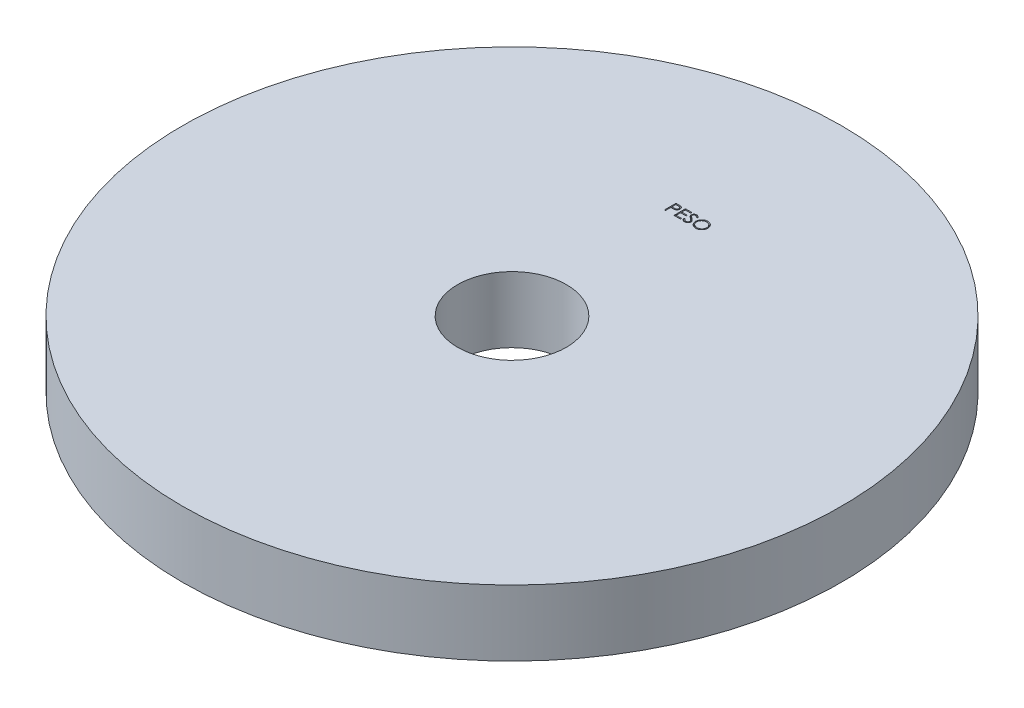
from build123d import *

# Parameters (mm, degrees)
ESBO_O1_R                = 100
ESBO_O1_R_2              = 16.5
RESSALTO_EXTRUS_O1_DEPTH = 20
CORTE_EXTRUS_O1_DEPTH    = 1


with BuildPart() as part:
    # Esboço1 → Ressalto-extrusão1 (new body)
    with BuildSketch(Plane(origin=(0, 0, 0), x_dir=(1, 0, 0), z_dir=(0, 1, 0))):
        Circle(ESBO_O1_R)
        Circle(ESBO_O1_R_2, mode=Mode.SUBTRACT)
    extrude(amount=RESSALTO_EXTRUS_O1_DEPTH)

    # Esboço2 → Corte-extrusão1 (cut)
    with BuildSketch(Plane(origin=(0, 20, 0), x_dir=(1, 0, 0), z_dir=(0, 1, 0))):
        with BuildLine():
            Line((-4.728102869, 54.494159365), (-4.041704632, 54.494159365))
            add(Edge.make_bspline(
                [(-4.041704632, 54.494159365), (-3.994493726, 54.494107469), (-3.904035533, 54.494008034), (-3.774320477, 54.490993288), (-3.656510746, 54.486966596), (-3.550860365, 54.481384703), (-3.457044267, 54.474788112), (-3.375486967, 54.465536073), (-3.305547411, 54.455875777), (-3.263640961, 54.446054371), (-3.244529151, 54.441575231)],
                knots=[0, 0, 0, 0, 0.000141628, 0.000271366, 0.00038923, 0.000495248, 0.00058876, 0.000671296, 0.000741499, 0.00080036, 0.00080036, 0.00080036, 0.00080036], degree=3))
            add(Edge.make_bspline(
                [(-3.244529151, 54.441575231), (-3.220335617, 54.434953281), (-3.17251864, 54.421865419), (-3.103617597, 54.395651696), (-3.038063752, 54.364569531), (-2.975632193, 54.329145591), (-2.91709011, 54.287860027), (-2.861564069, 54.242386409), (-2.809544089, 54.19167484), (-2.761322697, 54.1362941), (-2.717037899, 54.077173891), (-2.678908217, 54.013431661), (-2.64698099, 53.946140357), (-2.619597718, 53.875346786), (-2.599889264, 53.800456463), (-2.585042364, 53.72198975), (-2.575618736, 53.63995506), (-2.574716175, 53.583895192), (-2.574256715, 53.555357282)],
                knots=[0, 0, 0, 0, 7.5216e-05, 0.00014866, 0.000220794, 0.000292713, 0.000363707, 0.000435434, 0.000507823, 0.000581364, 0.000655543, 0.000729131, 0.000803767, 0.000878771, 0.000956497, 0.001035702, 0.001118238, 0.001203821, 0.001203821, 0.001203821, 0.001203821], degree=3))
            add(Edge.make_bspline(
                [(-2.574256715, 53.555357282), (-2.57467814, 53.526579505), (-2.575502686, 53.470273841), (-2.585398971, 53.387901053), (-2.598729163, 53.309182663), (-2.619226215, 53.234293213), (-2.646071888, 53.163677442), (-2.677563941, 53.09625621), (-2.715547472, 53.033176538), (-2.759192301, 52.974209421), (-2.807743896, 52.919299508), (-2.860996834, 52.868844714), (-2.918736126, 52.823140375), (-2.980778274, 52.782084032), (-3.047728123, 52.746627752), (-3.118570277, 52.714870447), (-3.193920493, 52.688199387), (-3.246063007, 52.674169325), (-3.272574023, 52.667035968)],
                knots=[0, 0, 0, 0, 8.6284e-05, 0.00016882, 0.000248587, 0.000325638, 0.000401297, 0.000474998, 0.000548586, 0.000621785, 0.0006948, 0.0007682, 0.000841564, 0.000915458, 0.000991056, 0.00106858, 0.00114819, 0.001230532, 0.001230532, 0.001230532, 0.001230532], degree=3))
            add(Edge.make_bspline(
                [(-3.272574023, 52.667035968), (-3.294501357, 52.662372987), (-3.342556384, 52.652153793), (-3.421699106, 52.640745336), (-3.513844492, 52.631007735), (-3.618866772, 52.623706598), (-3.736671677, 52.617456229), (-3.867322935, 52.612488135), (-4.011077012, 52.609758281), (-4.111348256, 52.609617489), (-4.163699824, 52.609543981)],
                knots=[0, 0, 0, 0, 6.7238e-05, 0.000147357, 0.000239727, 0.000345177, 0.000463135, 0.000593636, 0.000737393, 0.000894446, 0.000894446, 0.000894446, 0.000894446], degree=3))
            Line((-4.163699824, 52.609543981), (-4.414000305, 52.609543981))
            Line((-4.414000305, 52.609543981), (-4.414000305, 50.994159365))
            Line((-4.414000305, 50.994159365), (-4.728102869, 50.994159365))
            Line((-4.728102869, 50.994159365), (-4.728102869, 54.494159365))
        make_face()
        with BuildLine():
            Line((-4.414000305, 54.135185006), (-4.414000305, 52.96851834))
            Line((-4.414000305, 52.96851834), (-3.801219856, 52.960806))
            add(Edge.make_bspline(
                [(-3.801219856, 52.960806), (-3.77129993, 52.960790536), (-3.713540131, 52.960760684), (-3.630103907, 52.964745908), (-3.55269462, 52.96934644), (-3.481550045, 52.976082364), (-3.41663811, 52.985603621), (-3.357850581, 52.995215359), (-3.305643298, 53.009120722), (-3.244544097, 53.027843791), (-3.176460749, 53.059776407), (-3.102393201, 53.106126297), (-3.039622614, 53.165207005), (-2.985304317, 53.231634836), (-2.94219844, 53.305533966), (-2.910642447, 53.384602902), (-2.89210129, 53.468030752), (-2.889615096, 53.525118891), (-2.888359279, 53.553955039)],
                knots=[0, 0, 0, 0, 8.9746e-05, 0.000173253, 0.000250533, 0.00032239, 0.000387534, 0.00044736, 0.000500926, 0.000549486, 0.000638903, 0.000725641, 0.000810488, 0.000896226, 0.000982324, 0.00106604, 0.001150757, 0.001237226, 0.001237226, 0.001237226, 0.001237226], degree=3))
            add(Edge.make_bspline(
                [(-2.888359279, 53.553955039), (-2.889621926, 53.582093552), (-2.892131911, 53.638029434), (-2.910787774, 53.720008195), (-2.942137088, 53.798243899), (-2.985593682, 53.871216984), (-3.038334812, 53.937405788), (-3.099634155, 53.994902916), (-3.169347417, 54.041124618), (-3.234195648, 54.0709579), (-3.291796834, 54.089173175), (-3.341828794, 54.101918016), (-3.398319468, 54.112093622), (-3.461287248, 54.120333125), (-3.530244082, 54.127386586), (-3.605782396, 54.132172563), (-3.68761604, 54.13497402), (-3.744426611, 54.135112975), (-3.773876106, 54.135185006)],
                knots=[0, 0, 0, 0, 8.4371e-05, 0.000167719, 0.000250783, 0.000336277, 0.000421575, 0.000503926, 0.000587348, 0.000671427, 0.000717102, 0.000768457, 0.000826213, 0.000889178, 0.000958942, 0.001034123, 0.001116202, 0.001204546, 0.001204546, 0.001204546, 0.001204546], degree=3))
            Line((-3.773876106, 54.135185006), (-4.414000305, 54.135185006))
        make_face(mode=Mode.SUBTRACT)
        Polygon((-1.856307997, 54.494159365), (0.118050977, 54.494159365), (0.118050977, 54.135185006), (-1.542205433, 54.135185006), (-1.542205433, 53.05826193), (0.118050977, 53.05826193), (0.118050977, 52.699287571), (-1.542205433, 52.699287571), (-1.542205433, 51.353133724), (0.118050977, 51.353133724), (0.118050977, 50.994159365), (-1.856307997, 50.994159365), align=None)
        with BuildLine():
            Line((0.387281746, 51.669339654), (0.683155144, 51.846723468))
            add(Edge.make_bspline(
                [(0.683155144, 51.846723468), (0.710673381, 51.800659083), (0.763397262, 51.712401499), (0.851348621, 51.593143459), (0.942481532, 51.491781302), (1.037470865, 51.408904694), (1.135736814, 51.343655808), (1.237920867, 51.297453576), (1.343678678, 51.268637601), (1.4156525, 51.265137514), (1.451584631, 51.263390135)],
                knots=[0, 0, 0, 0, 0.000160901, 0.00030828, 0.000443778, 0.00056903, 0.000685513, 0.000796284, 0.00090427, 0.001011928, 0.001011928, 0.001011928, 0.001011928], degree=3))
            add(Edge.make_bspline(
                [(1.451584631, 51.263390135), (1.482271491, 51.264244807), (1.543108264, 51.265939197), (1.632670507, 51.282219999), (1.71965231, 51.307232128), (1.802260947, 51.34305306), (1.879356562, 51.386391546), (1.946963257, 51.438737723), (2.00540937, 51.497343929), (2.053218485, 51.562726584), (2.08989852, 51.633043732), (2.118090589, 51.705219683), (2.133735662, 51.780388252), (2.136092416, 51.830998715), (2.137281746, 51.856539173)],
                knots=[0, 0, 0, 0, 9.1978e-05, 0.000182347, 0.000272202, 0.000362975, 0.000451852, 0.000536835, 0.000618639, 0.000699414, 0.000778765, 0.000855983, 0.0009312, 0.001007828, 0.001007828, 0.001007828, 0.001007828], degree=3))
            add(Edge.make_bspline(
                [(2.137281746, 51.856539173), (2.135807436, 51.885680023), (2.132810377, 51.944919112), (2.107478897, 52.032318765), (2.06762965, 52.118811335), (2.030867007, 52.172312601), (2.011780945, 52.200088853)],
                knots=[0, 0, 0, 0, 8.7281e-05, 0.000177429, 0.000270909, 0.000371844, 0.000371844, 0.000371844, 0.000371844], degree=3))
            add(Edge.make_bspline(
                [(2.011780945, 52.200088853), (1.996110331, 52.220135676), (1.963211837, 52.262221475), (1.906654324, 52.32486671), (1.84028821, 52.389485129), (1.766384655, 52.458544186), (1.682251566, 52.528831983), (1.590524051, 52.603700261), (1.488860193, 52.680301838), (1.417560696, 52.731674403), (1.38077133, 52.758181801)],
                knots=[0, 0, 0, 0, 7.6319e-05, 0.000160223, 0.000252933, 0.000354147, 0.000463581, 0.000581729, 0.000709336, 0.000845369, 0.000845369, 0.000845369, 0.000845369], degree=3))
            add(Edge.make_bspline(
                [(1.38077133, 52.758181801), (1.343947333, 52.784410389), (1.273542657, 52.834557451), (1.175084075, 52.908981735), (1.087039612, 52.977025605), (1.009800595, 53.039329617), (0.943400998, 53.095902222), (0.887317587, 53.146200161), (0.84297903, 53.191583722), (0.818323449, 53.221025063), (0.807253701, 53.2342435)],
                knots=[0, 0, 0, 0, 0.000135623, 0.000259301, 0.000370234, 0.000469439, 0.00055697, 0.000631911, 0.000695377, 0.00074709, 0.00074709, 0.00074709, 0.00074709], degree=3))
            add(Edge.make_bspline(
                [(0.807253701, 53.2342435), (0.791781156, 53.254844537), (0.761352319, 53.295359241), (0.721186314, 53.358684098), (0.687047151, 53.423507364), (0.660284819, 53.490003228), (0.6377486, 53.557238157), (0.62259067, 53.626089403), (0.613099273, 53.696248021), (0.612127286, 53.743461522), (0.611640721, 53.767096064)],
                knots=[0, 0, 0, 0, 7.727e-05, 0.000151962, 0.000224716, 0.000296717, 0.00036678, 0.0004372, 0.000507902, 0.000578771, 0.000578771, 0.000578771, 0.000578771], degree=3))
            add(Edge.make_bspline(
                [(0.611640721, 53.767096064), (0.61294593, 53.804125839), (0.61552845, 53.877393902), (0.637368967, 53.984424733), (0.671841861, 54.08661115), (0.720136748, 54.182941484), (0.782394101, 54.270907465), (0.854440076, 54.351520952), (0.940251562, 54.419289534), (1.034404185, 54.478501592), (1.137460557, 54.524847518), (1.245451461, 54.559808498), (1.358548533, 54.579617755), (1.435151667, 54.58246052), (1.474020528, 54.583902955)],
                knots=[0, 0, 0, 0, 0.000110999, 0.000219625, 0.000326272, 0.00043382, 0.000541574, 0.000648775, 0.000756959, 0.000868438, 0.000981703, 0.00109501, 0.001208203, 0.0013248, 0.0013248, 0.0013248, 0.0013248], degree=3))
            add(Edge.make_bspline(
                [(1.474020528, 54.583902955), (1.515264629, 54.582480404), (1.59728598, 54.579651402), (1.717935196, 54.555053871), (1.834095912, 54.514353199), (1.927539177, 54.468164541), (2.000671939, 54.422033126), (2.056444671, 54.380013301), (2.112962122, 54.331638193), (2.170680177, 54.276778947), (2.228620836, 54.214932196), (2.287644289, 54.146521507), (2.347888557, 54.071964951), (2.386644418, 54.01874045), (2.406512516, 53.991455039)],
                knots=[0, 0, 0, 0, 0.000123638, 0.000245877, 0.000367608, 0.000492088, 0.000557638, 0.000626769, 0.000701372, 0.00078072, 0.000865532, 0.000955497, 0.001051745, 0.001152989, 0.001152989, 0.001152989, 0.001152989], degree=3))
            Line((2.406512516, 53.991455039), (2.122558189, 53.776210647))
            add(Edge.make_bspline(
                [(2.122558189, 53.776210647), (2.105412256, 53.798299338), (2.072393199, 53.840836991), (2.022263712, 53.900408307), (1.975015064, 53.954824786), (1.928464664, 54.002089914), (1.885071033, 54.044792048), (1.842953991, 54.081351804), (1.80271964, 54.1121274), (1.752002729, 54.14497096), (1.688285011, 54.177527463), (1.608300474, 54.205076541), (1.524714199, 54.221631603), (1.467784568, 54.223820491), (1.438964439, 54.224928596)],
                knots=[0, 0, 0, 0, 8.3877e-05, 0.000161528, 0.000233552, 0.000299993, 0.000360485, 0.000416152, 0.000467195, 0.000512312, 0.000597287, 0.000681099, 0.000765389, 0.000851809, 0.000851809, 0.000851809, 0.000851809], degree=3))
            add(Edge.make_bspline(
                [(1.438964439, 54.224928596), (1.402807916, 54.223716896), (1.333083469, 54.221380247), (1.234093233, 54.195860262), (1.144999308, 54.155678401), (1.068446743, 54.099363423), (1.004709766, 54.032642431), (0.958604307, 53.955863576), (0.930854142, 53.871081173), (0.927467863, 53.811939517), (0.925743285, 53.781819622)],
                knots=[0, 0, 0, 0, 0.000108248, 0.000208746, 0.00030443, 0.000399793, 0.000492054, 0.00057947, 0.000666386, 0.000756591, 0.000756591, 0.000756591, 0.000756591], degree=3))
            add(Edge.make_bspline(
                [(0.925743285, 53.781819622), (0.926136411, 53.763068143), (0.926923307, 53.725534524), (0.937898105, 53.670083102), (0.951997434, 53.614771763), (0.974340066, 53.55984918), (1.00518537, 53.504354821), (1.045690545, 53.447333083), (1.096703857, 53.388281374), (1.13578087, 53.349874001), (1.156412355, 53.329596064)],
                knots=[0, 0, 0, 0, 5.616e-05, 0.000112411, 0.000169046, 0.000227244, 0.000289691, 0.000359134, 0.000436702, 0.000523463, 0.000523463, 0.000523463, 0.000523463], degree=3))
            add(Edge.make_bspline(
                [(1.156412355, 53.329596064), (1.164073728, 53.322759038), (1.182275395, 53.30651583), (1.215551321, 53.279923549), (1.259494119, 53.247120777), (1.31295632, 53.206533461), (1.376923682, 53.159451998), (1.451403238, 53.106478386), (1.535564771, 53.045892927), (1.595286687, 53.003535387), (1.62686508, 52.981138532)],
                knots=[0, 0, 0, 0, 3.0802e-05, 7.3177e-05, 0.000127725, 0.000195314, 0.000274544, 0.000365991, 0.000469501, 0.000585644, 0.000585644, 0.000585644, 0.000585644], degree=3))
            add(Edge.make_bspline(
                [(1.62686508, 52.981138532), (1.664850993, 52.953497173), (1.738405449, 52.899973511), (1.843063029, 52.819557831), (1.937956837, 52.740910062), (2.023420041, 52.664532455), (2.100296949, 52.591004362), (2.16773467, 52.519441182), (2.22642035, 52.450355609), (2.289599569, 52.361783033), (2.354157388, 52.253001949), (2.409598896, 52.119723711), (2.444557243, 51.98592739), (2.449128759, 51.896000554), (2.45138431, 51.851631321)],
                knots=[0, 0, 0, 0, 0.000140932, 0.000272896, 0.000395881, 0.000510584, 0.000616697, 0.000714904, 0.000805482, 0.000888372, 0.001041088, 0.001183793, 0.001320341, 0.001453327, 0.001453327, 0.001453327, 0.001453327], degree=3))
            add(Edge.make_bspline(
                [(2.45138431, 51.851631321), (2.450727172, 51.820252955), (2.449425657, 51.758105572), (2.434464743, 51.666850495), (2.412545078, 51.578219625), (2.379507844, 51.493308513), (2.339184686, 51.41056375), (2.288018438, 51.33215585), (2.228710753, 51.256349451), (2.160676989, 51.18516596), (2.086231086, 51.119819764), (2.007547392, 51.061690702), (1.924497119, 51.013222379), (1.837530802, 50.973671537), (1.746628465, 50.942738019), (1.651820681, 50.92032515), (1.55295117, 50.906569439), (1.485750689, 50.905141678), (1.451584631, 50.904415776)],
                knots=[0, 0, 0, 0, 9.4044e-05, 0.000186263, 0.000276729, 0.000367488, 0.000459046, 0.000552398, 0.000647774, 0.000747454, 0.000847311, 0.000944634, 0.001040472, 0.001135227, 0.001230788, 0.001328063, 0.00142712, 0.00152957, 0.00152957, 0.00152957, 0.00152957], degree=3))
            add(Edge.make_bspline(
                [(1.451584631, 50.904415776), (1.425149288, 50.904926957), (1.372611528, 50.905942883), (1.294902046, 50.914924163), (1.218762457, 50.927631267), (1.145148175, 50.947805337), (1.073110763, 50.972282314), (1.002963529, 51.002420646), (0.934672475, 51.038537848), (0.867854892, 51.079832872), (0.802680717, 51.127890617), (0.739761249, 51.183864113), (0.677032064, 51.246209618), (0.616344668, 51.316620182), (0.556471523, 51.393958265), (0.498593114, 51.478947448), (0.441511396, 51.571124802), (0.405695928, 51.635989887), (0.387281746, 51.669339654)],
                knots=[0, 0, 0, 0, 7.9276e-05, 0.000157554, 0.000234438, 0.000310629, 0.000386236, 0.000462555, 0.000539392, 0.000617798, 0.000698008, 0.000781971, 0.000870217, 0.00096315, 0.001060616, 0.001163492, 0.001271478, 0.00138575, 0.00138575, 0.00138575, 0.00138575], degree=3))
        make_face()
        with BuildLine():
            add(Edge.make_bspline(
                [(4.807153541, 54.583902955), (4.871961647, 54.582261476), (4.999250114, 54.579037475), (5.186325012, 54.554358371), (5.364920107, 54.511662981), (5.536490246, 54.454799999), (5.698983222, 54.378945614), (5.853622115, 54.287260465), (6.000038989, 54.178784006), (6.13626037, 54.05435478), (6.260917321, 53.918971326), (6.370743207, 53.774493416), (6.462785501, 53.621794613), (6.538371288, 53.461333783), (6.597669897, 53.293473815), (6.638588941, 53.117319812), (6.664727091, 52.934013122), (6.667782869, 52.808986257), (6.669333028, 52.745561609)],
                knots=[0, 0, 0, 0, 0.000194393, 0.000381804, 0.00056479, 0.000744601, 0.000923091, 0.001101652, 0.001283106, 0.001468738, 0.001654324, 0.001834514, 0.002012231, 0.002188181, 0.002365797, 0.002545211, 0.002729936, 0.002920126, 0.002920126, 0.002920126, 0.002920126], degree=3))
            add(Edge.make_bspline(
                [(6.669333028, 52.745561609), (6.667783096, 52.682604163), (6.664727999, 52.558507742), (6.638559222, 52.376364298), (6.597518222, 52.201273602), (6.538921956, 52.033527949), (6.463696477, 51.872950385), (6.371041306, 51.719963431), (6.261900095, 51.574516933), (6.137693244, 51.438204268), (6.002292202, 51.313206797), (5.857061935, 51.204287921), (5.705268615, 51.110563797), (5.544958907, 51.035780123), (5.37825887, 50.976008202), (5.203676547, 50.935255572), (5.022029993, 50.908968529), (4.89815899, 50.905950013), (4.835198413, 50.904415776)],
                knots=[0, 0, 0, 0, 0.000188789, 0.000372126, 0.000550857, 0.00072758, 0.000904164, 0.001081881, 0.001263191, 0.001448823, 0.00163441, 0.001815159, 0.001992641, 0.002168591, 0.002344885, 0.002522934, 0.002705576, 0.002894365, 0.002894365, 0.002894365, 0.002894365], degree=3))
            add(Edge.make_bspline(
                [(4.835198413, 50.904415776), (4.771774094, 50.905965163), (4.646747878, 50.909019416), (4.463210843, 50.935200821), (4.286933099, 50.976142125), (4.118418748, 51.034651561), (3.957573818, 51.110268792), (3.804083735, 51.202473171), (3.658564588, 51.311880312), (3.522222842, 51.436046887), (3.397473643, 51.571218439), (3.288714268, 51.716052694), (3.196489154, 51.867708151), (3.121125822, 52.026605675), (3.061461363, 52.191977117), (3.020756544, 52.364925595), (2.994420592, 52.544465101), (2.991385746, 52.666707999), (2.989845849, 52.728734686)],
                knots=[0, 0, 0, 0, 0.00019019, 0.000374915, 0.000555011, 0.000732396, 0.00090898, 0.001087298, 0.001268608, 0.00145424, 0.001639827, 0.001819595, 0.001996712, 0.002171394, 0.002346367, 0.002523053, 0.002703612, 0.002889599, 0.002889599, 0.002889599, 0.002889599], degree=3))
            add(Edge.make_bspline(
                [(2.989845849, 52.728734686), (2.990380484, 52.770367355), (2.991443011, 52.853107479), (3.004234703, 52.975974079), (3.022796404, 53.096864737), (3.049398317, 53.215435684), (3.084189984, 53.331396669), (3.125242011, 53.445547432), (3.175381857, 53.556731156), (3.232062505, 53.665474547), (3.295324313, 53.770082453), (3.365200062, 53.868962036), (3.439235431, 53.962943033), (3.520398824, 54.049590037), (3.606015269, 54.131423693), (3.697473648, 54.20718641), (3.794215892, 54.277561361), (3.896658272, 54.340981703), (4.002276547, 54.398340837), (4.111153324, 54.447562688), (4.221809896, 54.48980875), (4.334764544, 54.524049575), (4.449717316, 54.551081611), (4.5669191, 54.569488965), (4.686276527, 54.582313282), (4.766687846, 54.583370784), (4.807153541, 54.583902955)],
                knots=[0, 0, 0, 0, 0.000124849, 0.000248123, 0.000370193, 0.00049164, 0.000612319, 0.000733199, 0.000855287, 0.000977905, 0.001100913, 0.001221706, 0.001340948, 0.001459521, 0.001577551, 0.001696047, 0.001815534, 0.001936153, 0.002057243, 0.002175846, 0.002294342, 0.002412335, 0.002529682, 0.00264829, 0.002768075, 0.00288942, 0.00288942, 0.00288942, 0.00288942], degree=3))
        make_face()
        with BuildLine():
            add(Edge.make_bspline(
                [(4.822578221, 54.224928596), (4.789363587, 54.224523706), (4.723251854, 54.223717796), (4.624967318, 54.213102081), (4.527975384, 54.197972192), (4.432256022, 54.176390671), (4.338209733, 54.146986618), (4.244959891, 54.11314571), (4.153356838, 54.071924619), (4.06370298, 54.025351915), (3.976787904, 53.973802994), (3.894775203, 53.916831227), (3.817452559, 53.855772673), (3.745009292, 53.790484836), (3.67765812, 53.720635234), (3.614073419, 53.647282798), (3.556803837, 53.568330907), (3.50431826, 53.4859205), (3.45735042, 53.400158919), (3.415585065, 53.311949056), (3.381421057, 53.220571369), (3.35355868, 53.127017212), (3.330458869, 53.031434752), (3.315824945, 52.933098903), (3.305092586, 52.832503791), (3.30433274, 52.764521937), (3.303948413, 52.73013693)],
                knots=[0, 0, 0, 0, 9.9599e-05, 0.000198245, 0.000296222, 0.00039402, 0.00049227, 0.000591646, 0.000691452, 0.000793368, 0.000894612, 0.000994383, 0.001092713, 0.00119001, 0.001286696, 0.001383657, 0.001480979, 0.001579008, 0.001676595, 0.001774142, 0.001871547, 0.001968922, 0.002066879, 0.00216624, 0.00226698, 0.002370083, 0.002370083, 0.002370083, 0.002370083], degree=3))
            add(Edge.make_bspline(
                [(3.303948413, 52.73013693), (3.305223275, 52.679574709), (3.307731323, 52.580103178), (3.329688893, 52.434335035), (3.363510867, 52.294246748), (3.413368234, 52.160604839), (3.475718848, 52.032260556), (3.552745739, 51.910352451), (3.644004824, 51.794847577), (3.747668351, 51.686552308), (3.860991057, 51.587706504), (3.981323787, 51.500943095), (4.107377395, 51.427532845), (4.239480598, 51.367727773), (4.376928137, 51.320338035), (4.520605688, 51.287859404), (4.669556147, 51.266483949), (4.771086802, 51.264431193), (4.822578221, 51.263390135)],
                knots=[0, 0, 0, 0, 0.000151605, 0.000298253, 0.000441263, 0.000583229, 0.000725274, 0.000868635, 0.001014928, 0.001166177, 0.001317744, 0.00146543, 0.001610576, 0.001754594, 0.001899821, 0.002045914, 0.002195936, 0.002350312, 0.002350312, 0.002350312, 0.002350312], degree=3))
            add(Edge.make_bspline(
                [(4.822578221, 51.263390135), (4.857187722, 51.263865639), (4.925828759, 51.264808707), (5.027924281, 51.274307384), (5.128180493, 51.289539253), (5.226456773, 51.311469909), (5.322641584, 51.338917115), (5.417136387, 51.371524843), (5.508934677, 51.412206047), (5.599194515, 51.457153999), (5.685590757, 51.508394156), (5.768066289, 51.563432306), (5.844542269, 51.624400926), (5.91693134, 51.688718739), (5.984559029, 51.757682587), (6.046968014, 51.831202809), (6.103948146, 51.909743466), (6.156413792, 51.992028872), (6.203217055, 52.078025124), (6.243996154, 52.166554802), (6.27859227, 52.257399912), (6.306520775, 52.350691483), (6.328406237, 52.446252332), (6.343486157, 52.54421041), (6.354034595, 52.644369753), (6.354829672, 52.712113609), (6.355230464, 52.746262731)],
                knots=[0, 0, 0, 0, 0.000103804, 0.000205874, 0.000307314, 0.000407849, 0.000507719, 0.000607281, 0.000707445, 0.000808723, 0.000909609, 0.001008589, 0.001105934, 0.001202762, 0.001298946, 0.001395452, 0.001491794, 0.001589823, 0.001688026, 0.001785277, 0.001882027, 0.001979402, 0.0020772, 0.002175869, 0.002276609, 0.002379011, 0.002379011, 0.002379011, 0.002379011], degree=3))
            add(Edge.make_bspline(
                [(6.355230464, 52.746262731), (6.354829351, 52.780178235), (6.35403367, 52.847455885), (6.343491195, 52.946916704), (6.328390305, 53.044169915), (6.306627597, 53.138833718), (6.278577443, 53.230932243), (6.243990113, 53.320378991), (6.203204813, 53.407507186), (6.156396589, 53.492101483), (6.103780765, 53.573276221), (6.046286522, 53.650878633), (5.982921174, 53.723451375), (5.915495149, 53.792786069), (5.842324264, 53.857403958), (5.76373997, 53.917326479), (5.680696292, 53.973999753), (5.592769056, 54.025125315), (5.502025103, 54.072339548), (5.408911145, 54.112790551), (5.314482045, 54.14716267), (5.218977933, 54.176479636), (5.121594954, 54.197887666), (5.022991126, 54.213115716), (4.923302867, 54.223714101), (4.856259647, 54.22452248), (4.822578221, 54.224928596)],
                knots=[0, 0, 0, 0, 0.000101701, 0.000201743, 0.00029972, 0.000396835, 0.000492868, 0.000588308, 0.000684288, 0.000781261, 0.000878109, 0.000974304, 0.001070733, 0.001166917, 0.001264269, 0.001363274, 0.001463228, 0.001565678, 0.001668217, 0.001769947, 0.001869982, 0.001969573, 0.002069423, 0.002168785, 0.002268827, 0.002369827, 0.002369827, 0.002369827, 0.002369827], degree=3))
        make_face(mode=Mode.SUBTRACT)
    extrude(amount=-CORTE_EXTRUS_O1_DEPTH, mode=Mode.SUBTRACT)


solid = part.part
